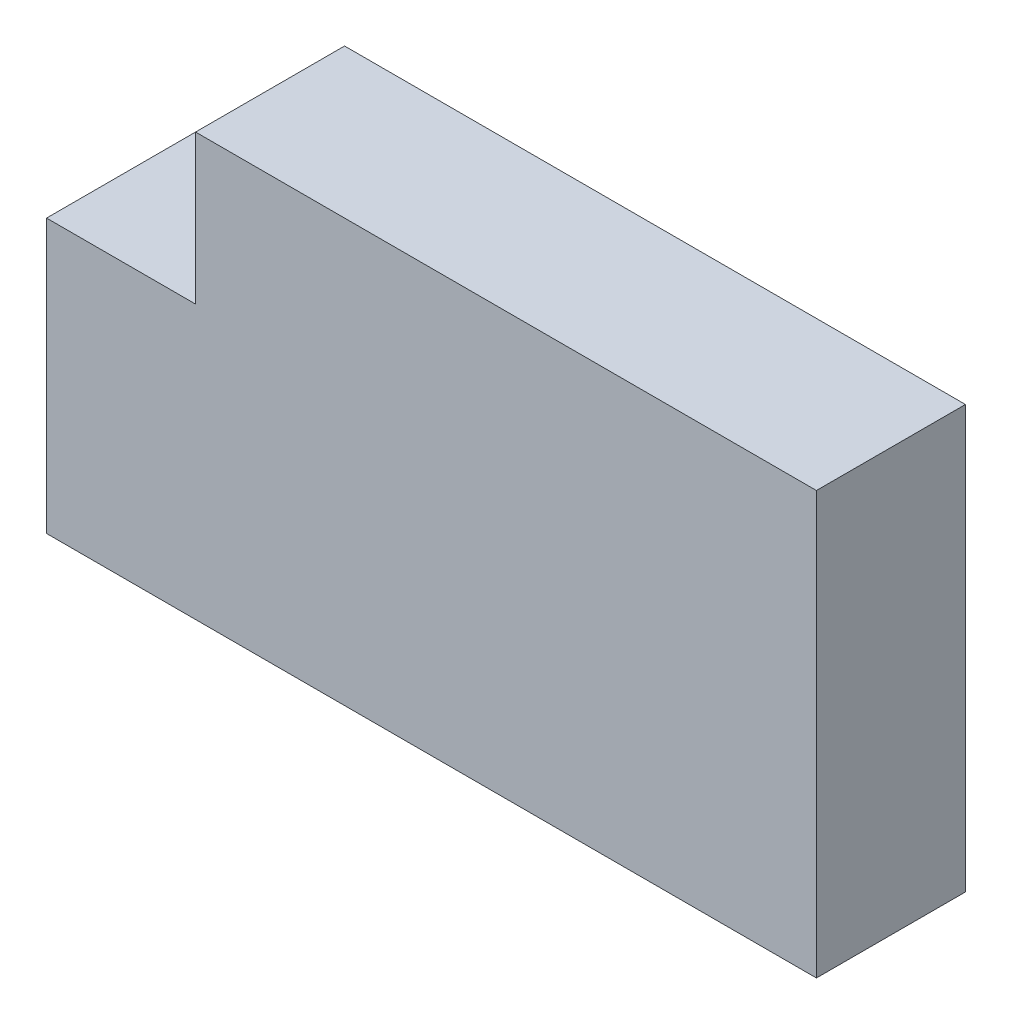
from build123d import *

# Parameters (mm, degrees)
RESSALTO_EXTRUS_O1_DEPTH = 6


with BuildPart() as part:
    # Esboço1 → Ressalto-extrusão1 (new body)
    with BuildSketch(Plane.XY):
        Polygon((0, 11), (0, 0), (31, 0), (31, 17), (6, 17), (6, 11), align=None)
    extrude(amount=RESSALTO_EXTRUS_O1_DEPTH)


solid = part.part
